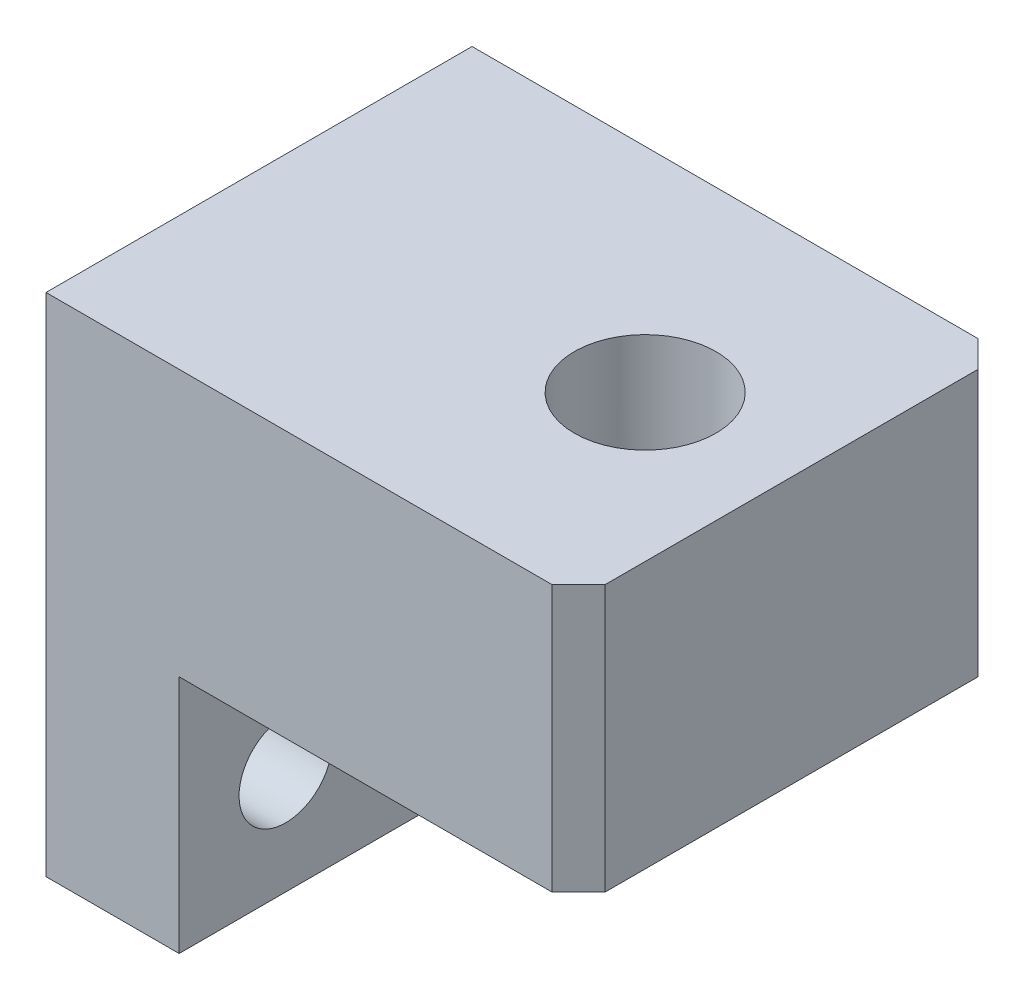
from build123d import *

# Parameters (mm, degrees)
BOSS_EXTRUDE1_DEPTH = 16
SKETCH2_R           = 2.658036829
CUT_EXTRUDE1_DEPTH  = 16
SKETCH3_R           = 1.75
CUT_EXTRUDE2_DEPTH  = 5
CHAMFER1_SIZE       = 1


with BuildPart() as part:
    # Sketch1 → Boss-Extrude1 (new body)
    with BuildSketch(Plane.XY):
        Polygon((-8.547486034, 7.854748603), (11.452513966, 7.854748603), (11.452513966, -2.145251397), (-3.547486034, -2.145251397), (-3.547486034, -11.145251397), (-8.547486034, -11.145251397), align=None)
    extrude(amount=BOSS_EXTRUDE1_DEPTH)

    # Sketch2 → Cut-Extrude1 (cut)
    with BuildSketch(Plane(origin=(0, 7.854748603, 0), x_dir=(1, 0, 0), z_dir=(0, 1, 0))):
        with Locations((5.952513966, -8)):
            Circle(SKETCH2_R)
    extrude(amount=-CUT_EXTRUDE1_DEPTH, mode=Mode.SUBTRACT)

    # Sketch3 → Cut-Extrude2 (cut)
    with BuildSketch(Plane(origin=(-3.547486034, 0, 0), x_dir=(0, 0, -1), z_dir=(1, 0, 0))):
        with Locations((-12, -7.145251397)):
            Circle(SKETCH3_R)
        with Locations((-4, -7.145251397)):
            Circle(SKETCH3_R)
    extrude(amount=-CUT_EXTRUDE2_DEPTH, mode=Mode.SUBTRACT)

    # Chamfer1
    chamfer1_edges = [part.edges().sort_by_distance(p)[0] for p in [
        (11.452513966, 2.854748603, 16),
        (11.452513966, 2.854748603, 0),
    ]]
    chamfer(chamfer1_edges, length=CHAMFER1_SIZE)


solid = part.part
